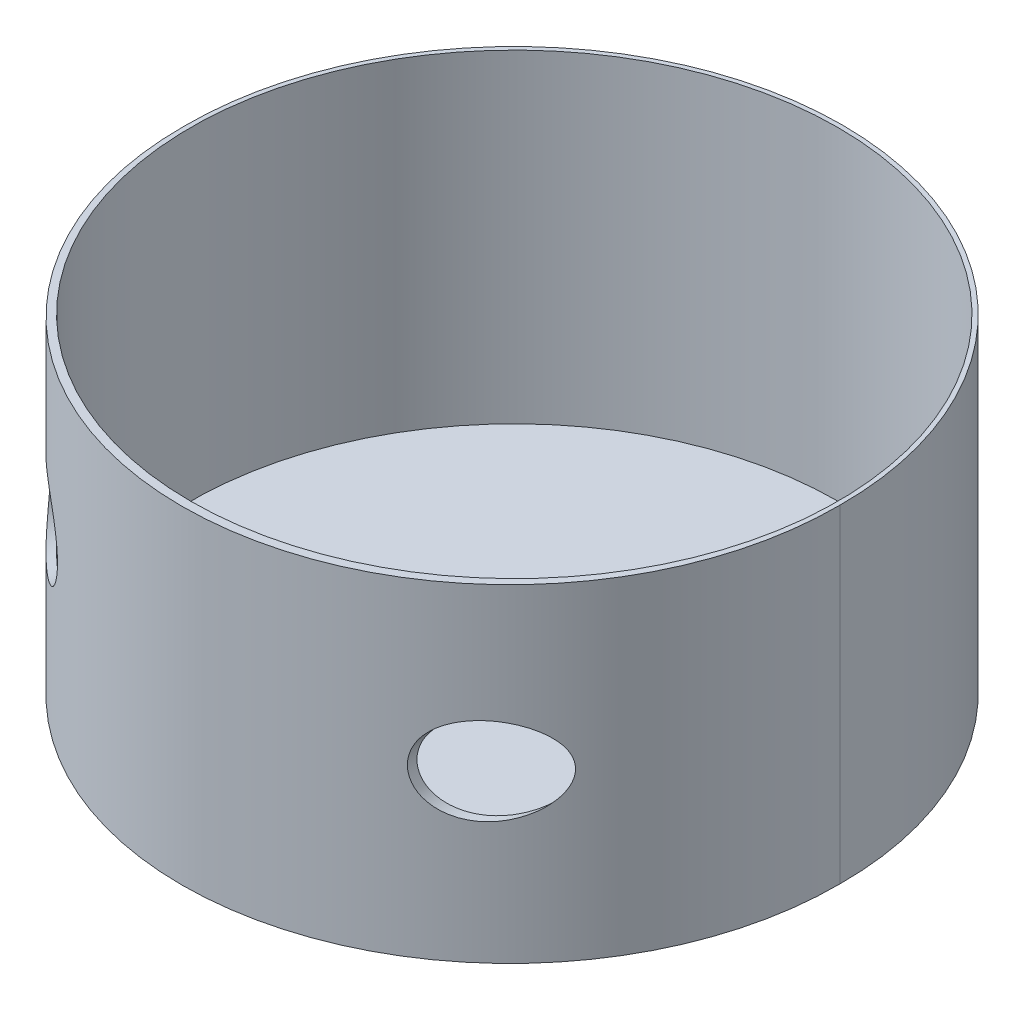
from build123d import *

# Parameters (mm, degrees)
ESQUISSE2_R             = 150
BOSS_EXTRU_1_DEPTH      = 150
ESQUISSE3_R             = 148
ENL_V_MAT_EXTRU_1_DEPTH = 148
ESQUISSE5_R             = 150
BOSS_EXTRU_2_DEPTH      = 150
ESQUISSE6_R             = 148
ENL_V_MAT_EXTRU_2_DEPTH = 177
ESQUISSE7_R             = 148
BOSS_EXTRU_3_DEPTH      = 2
ESQUISSE9_R             = 20
ENL_V_MAT_EXTRU_3_DEPTH = 200


with BuildPart() as part:
    # Esquisse2 → Boss.-Extru.1 (new body)
    with BuildSketch(Plane(origin=(0, 0, 0), x_dir=(1, 0, 0), z_dir=(0, 1, 0))):
        Circle(ESQUISSE2_R)
    extrude(amount=BOSS_EXTRU_1_DEPTH)

    # Esquisse3 → Enlèv. mat.-Extru.1 (cut)
    with BuildSketch(Plane(origin=(0, 0, 0), x_dir=(1, 0, 0), z_dir=(0, 1, 0))):
        Circle(ESQUISSE3_R)
    extrude(amount=ENL_V_MAT_EXTRU_1_DEPTH, mode=Mode.SUBTRACT)

    # Esquisse5 → Boss.-Extru.2 (add)
    with BuildSketch(Plane(origin=(0, 150, 0), x_dir=(1, 0, 0), z_dir=(0, 1, 0))):
        with Locations((0, -2)):
            Circle(ESQUISSE5_R)
    extrude(amount=-BOSS_EXTRU_2_DEPTH)

    # Esquisse6 → Enlèv. mat.-Extru.2 (cut)
    with BuildSketch(Plane(origin=(0, 0, 0), x_dir=(1, 0, 0), z_dir=(0, 1, 0))):
        Circle(ESQUISSE6_R)
    extrude(amount=ENL_V_MAT_EXTRU_2_DEPTH, mode=Mode.SUBTRACT)

    # Esquisse7 → Boss.-Extru.3 (add)
    with BuildSketch(Plane.XZ):
        Circle(ESQUISSE7_R)
    extrude(amount=-BOSS_EXTRU_3_DEPTH)

    # Esquisse9 → Enlèv. mat.-Extru.3 (cut)
    with BuildSketch(Plane.XY):
        with Locations((-100, 76)):
            Circle(ESQUISSE9_R)
        with Locations((100, 76)):
            Circle(ESQUISSE9_R)
    extrude(amount=ENL_V_MAT_EXTRU_3_DEPTH, mode=Mode.SUBTRACT)


solid = part.part
